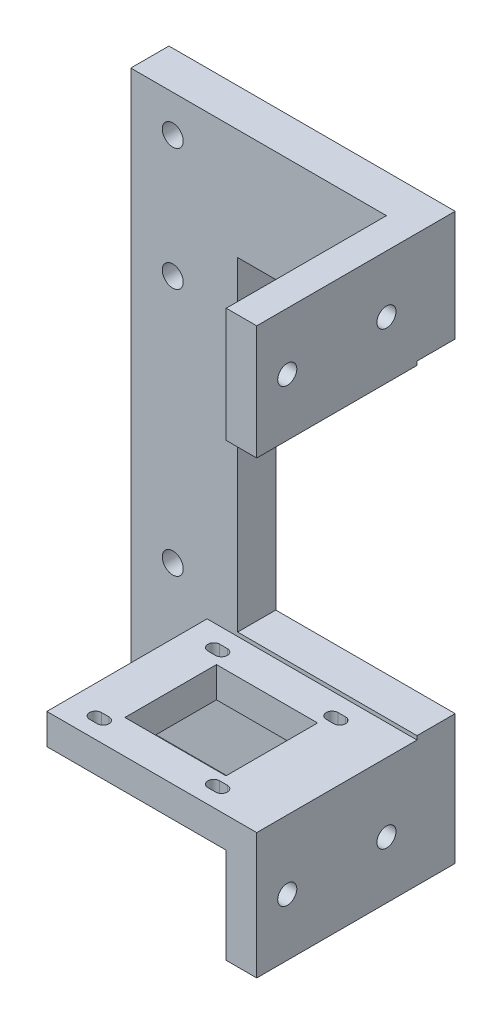
from build123d import *

# Parameters (mm, degrees)
SKETCH1_W           = 75
SKETCH1_H           = 148
BOSS_EXTRUDE1_DEPTH = 10
SKETCH2_W           = 55
SKETCH2_H           = 8
BOSS_EXTRUDE2_DEPTH = 42
SKETCH3_W           = 26.5
SKETCH3_H           = 24
CUT_EXTRUDE1_DEPTH  = 8
SKETCH4_W           = 8
SKETCH4_H           = 30
SKETCH4_H_2         = 25
BOSS_EXTRUDE3_DEPTH = 42
SKETCH5_R           = 2.5
CUT_EXTRUDE2_DEPTH  = 8
CUT_EXTRUDE3_DEPTH  = 8
SKETCH10_R          = 2.75
CUT_EXTRUDE5_DEPTH  = 10
SKETCH11_W          = 47
SKETCH11_H          = 85
CUT_EXTRUDE6_DEPTH  = 10


with BuildPart() as part:
    # Sketch1 → Boss-Extrude1 (new body)
    with BuildSketch(Plane.XY):
        with Locations((27.5, -70)):
            Rectangle(SKETCH1_W, SKETCH1_H)
    extrude(amount=BOSS_EXTRUDE1_DEPTH)

    # Sketch2 → Boss-Extrude2 (add)
    with BuildSketch(Plane.XY.offset(10)):
        with Locations((37.5, -115)):
            Rectangle(SKETCH2_W, SKETCH2_H)
    extrude(amount=BOSS_EXTRUDE2_DEPTH)

    # Sketch3 → Cut-Extrude1 (cut)
    with BuildSketch(Plane(origin=(0, -119, 0), x_dir=(-1, 0, 0), z_dir=(0, -1, 0))):
        with Locations((-34.85, -31.15)):
            Rectangle(SKETCH3_W, SKETCH3_H)
    extrude(amount=-CUT_EXTRUDE1_DEPTH, mode=Mode.SUBTRACT)

    # Sketch4 → Boss-Extrude3 (add)
    with BuildSketch(Plane.XY.offset(10)):
        with Locations((61, -11)):
            Rectangle(SKETCH4_W, SKETCH4_H)
        with Locations((61, -131.5)):
            Rectangle(SKETCH4_W, SKETCH4_H_2)
    extrude(amount=BOSS_EXTRUDE3_DEPTH)

    # Sketch5 → Cut-Extrude2 (cut)
    with BuildSketch(Plane.ZY.offset(-57)):
        with Locations((18, -11)):
            Circle(SKETCH5_R)
        with Locations((44, -11)):
            Circle(SKETCH5_R)
        with Locations((44, -129)):
            Circle(SKETCH5_R)
        with Locations((18, -129)):
            Circle(SKETCH5_R)
    extrude(amount=-CUT_EXTRUDE2_DEPTH, mode=Mode.SUBTRACT)

    # Sketch6 → Cut-Extrude3 (cut)
    with BuildSketch(Plane(origin=(0, -119, 0), x_dir=(-1, 0, 0), z_dir=(0, -1, 0))):
        with BuildLine():
            Line((-19.4, -45.1), (-17.4, -45.1))
            ThreePointArc((-17.4, -45.1), (-15.85, -46.65), (-17.4, -48.2))
            Line((-17.4, -48.2), (-19.4, -48.2))
            ThreePointArc((-19.4, -48.2), (-20.95, -46.65), (-19.4, -45.1))
        make_face()
        with BuildLine():
            Line((-19.4, -14.1), (-17.4, -14.1))
            ThreePointArc((-17.4, -14.1), (-15.85, -15.65), (-17.4, -17.2))
            Line((-17.4, -17.2), (-19.4, -17.2))
            ThreePointArc((-19.4, -17.2), (-20.95, -15.65), (-19.4, -14.1))
        make_face()
        with BuildLine():
            Line((-50.4, -45.1), (-48.4, -45.1))
            ThreePointArc((-48.4, -45.1), (-46.85, -46.65), (-48.4, -48.2))
            Line((-48.4, -48.2), (-50.4, -48.2))
            ThreePointArc((-50.4, -48.2), (-51.95, -46.65), (-50.4, -45.1))
        make_face()
        with BuildLine():
            Line((-50.4, -14.1), (-48.4, -14.1))
            ThreePointArc((-48.4, -14.1), (-46.85, -15.65), (-48.4, -17.2))
            Line((-48.4, -17.2), (-50.4, -17.2))
            ThreePointArc((-50.4, -17.2), (-51.95, -15.65), (-50.4, -14.1))
        make_face()
    extrude(amount=-CUT_EXTRUDE3_DEPTH, mode=Mode.SUBTRACT)

    # Sketch10 → Cut-Extrude5 (cut)
    with BuildSketch(Plane(origin=(0, 0, 0), x_dir=(-1, 0, 0), z_dir=(0, 0, -1))):
        with Locations((-1, -102.8)):
            Circle(SKETCH10_R)
        with Locations((-1, -134.8)):
            Circle(SKETCH10_R)
        with Locations((-1, -37.7)):
            Circle(SKETCH10_R)
        with Locations((-1, -5.7)):
            Circle(SKETCH10_R)
    extrude(amount=-CUT_EXTRUDE5_DEPTH, mode=Mode.SUBTRACT)

    # Sketch11 → Cut-Extrude6 (cut)
    with BuildSketch(Plane(origin=(0, 0, 0), x_dir=(-1, 0, 0), z_dir=(0, 0, -1))):
        with Locations((-41.5, -67.5)):
            Rectangle(SKETCH11_W, SKETCH11_H)
    extrude(amount=-CUT_EXTRUDE6_DEPTH, mode=Mode.SUBTRACT)


solid = part.part
